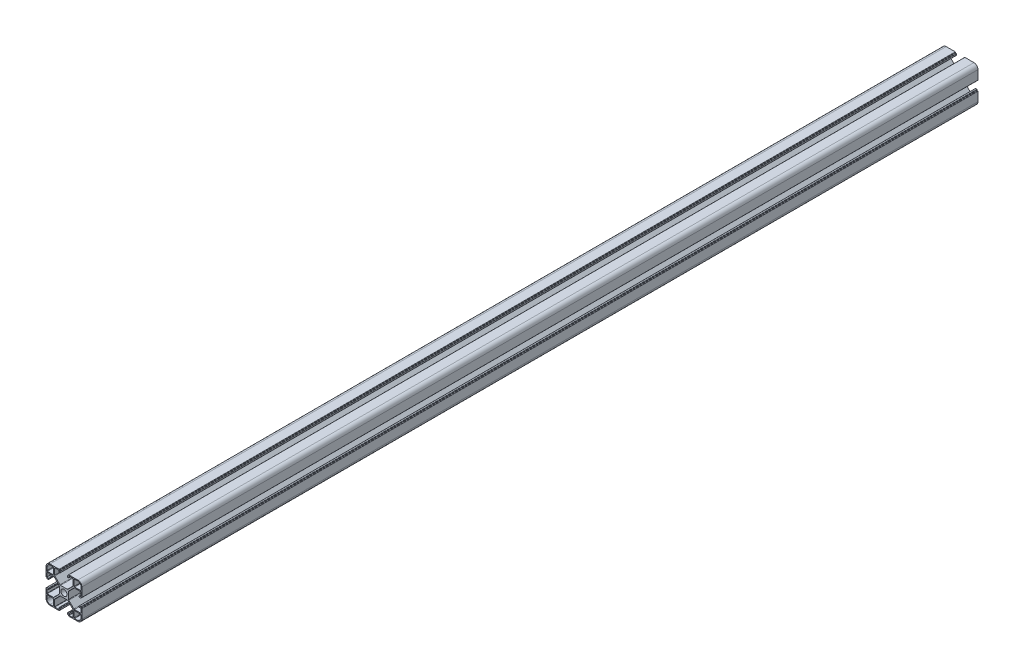
from build123d import *

# Parameters (mm, degrees)
SKETCH_1_R      = 3.4
EXTRUDE_1_DEPTH = 1000


with BuildPart() as part:
    # Эскиз1 → Бобышка-Вытянуть1 (new body)
    with BuildSketch(Plane.XY):
        with BuildLine():
            Line((-20, 10.4), (-20, 15.5))
            ThreePointArc((-20, 15.5), (-18.681980515, 18.681980515), (-15.5, 20))
            Line((-15.5, 20), (-10.4, 20))
            Line((-10.4, 20), (-5.4, 20))
            ThreePointArc((-5.4, 20), (-5.187867966, 19.912132034), (-5.1, 19.7))
            Line((-5.1, 19.7), (-5.1, 19.3))
            ThreePointArc((-5.1, 19.3), (-5.012132034, 19.087867966), (-4.8, 19))
            Line((-4.8, 19), (-4.4, 19))
            ThreePointArc((-4.4, 19), (-4.187867966, 18.912132034), (-4.1, 18.7))
            Line((-4.1, 18.7), (-4.1, 17.3))
            ThreePointArc((-4.1, 17.3), (-4.187867966, 17.087867966), (-4.4, 17))
            Line((-4.4, 17), (-5.3, 17))
            ThreePointArc((-5.3, 17), (-5.512132034, 17.087867966), (-5.6, 17.3))
            Line((-5.6, 17.3), (-5.6, 18.7))
            ThreePointArc((-5.6, 18.7), (-5.687867966, 18.912132034), (-5.9, 19))
            Line((-5.9, 19), (-10.1, 19))
            ThreePointArc((-10.1, 19), (-10.312132034, 18.912132034), (-10.4, 18.7))
            Line((-10.4, 18.7), (-10.4, 11.814213562))
            ThreePointArc((-10.4, 11.814213562), (-10.323879533, 11.43153013), (-10.107106781, 11.107106781))
            Line((-10.107106781, 11.107106781), (-4.492893219, 5.492893219))
            ThreePointArc((-4.492893219, 5.492893219), (-4.16846987, 5.276120467), (-3.785786438, 5.2))
            Line((-3.785786438, 5.2), (3.785786438, 5.2))
            ThreePointArc((3.785786438, 5.2), (4.16846987, 5.276120467), (4.492893219, 5.492893219))
            Line((4.492893219, 5.492893219), (10.107106781, 11.107106781))
            ThreePointArc((10.107106781, 11.107106781), (10.323879533, 11.43153013), (10.4, 11.814213562))
            Line((10.4, 11.814213562), (10.4, 18.7))
            ThreePointArc((10.4, 18.7), (10.312132034, 18.912132034), (10.1, 19))
            Line((10.1, 19), (5.9, 19))
            ThreePointArc((5.9, 19), (5.687867966, 18.912132034), (5.6, 18.7))
            Line((5.6, 18.7), (5.6, 17.3))
            ThreePointArc((5.6, 17.3), (5.512132034, 17.087867966), (5.3, 17))
            Line((5.3, 17), (4.4, 17))
            ThreePointArc((4.4, 17), (4.187867966, 17.087867966), (4.1, 17.3))
            Line((4.1, 17.3), (4.1, 18.7))
            ThreePointArc((4.1, 18.7), (4.187867966, 18.912132034), (4.4, 19))
            Line((4.4, 19), (4.8, 19))
            ThreePointArc((4.8, 19), (5.012132034, 19.087867966), (5.1, 19.3))
            Line((5.1, 19.3), (5.1, 19.7))
            ThreePointArc((5.1, 19.7), (5.187867966, 19.912132034), (5.4, 20))
            Line((5.4, 20), (10.4, 20))
            Line((10.4, 20), (15.5, 20))
            ThreePointArc((15.5, 20), (18.681980515, 18.681980515), (20, 15.5))
            Line((20, 15.5), (20, 10.4))
            Line((20, 10.4), (20, 5.4))
            ThreePointArc((20, 5.4), (19.912132034, 5.187867966), (19.7, 5.1))
            Line((19.7, 5.1), (19.3, 5.1))
            ThreePointArc((19.3, 5.1), (19.087867966, 5.012132034), (19, 4.8))
            Line((19, 4.8), (19, 4.4))
            ThreePointArc((19, 4.4), (18.912132034, 4.187867966), (18.7, 4.1))
            Line((18.7, 4.1), (17.3, 4.1))
            ThreePointArc((17.3, 4.1), (17.087867966, 4.187867966), (17, 4.4))
            Line((17, 4.4), (17, 5.3))
            ThreePointArc((17, 5.3), (17.087867966, 5.512132034), (17.3, 5.6))
            Line((17.3, 5.6), (18.7, 5.6))
            ThreePointArc((18.7, 5.6), (18.912132034, 5.687867966), (19, 5.9))
            Line((19, 5.9), (19, 10.1))
            ThreePointArc((19, 10.1), (18.912132034, 10.312132034), (18.7, 10.4))
            Line((18.7, 10.4), (11.814213562, 10.4))
            ThreePointArc((11.814213562, 10.4), (11.43153013, 10.323879533), (11.107106781, 10.107106781))
            Line((11.107106781, 10.107106781), (5.492893219, 4.492893219))
            ThreePointArc((5.492893219, 4.492893219), (5.276120467, 4.16846987), (5.2, 3.785786438))
            Line((5.2, 3.785786438), (5.2, -3.785786438))
            ThreePointArc((5.2, -3.785786438), (5.276120467, -4.16846987), (5.492893219, -4.492893219))
            Line((5.492893219, -4.492893219), (11.107106781, -10.107106781))
            ThreePointArc((11.107106781, -10.107106781), (11.43153013, -10.323879533), (11.814213562, -10.4))
            Line((11.814213562, -10.4), (18.7, -10.4))
            ThreePointArc((18.7, -10.4), (18.912132034, -10.312132034), (19, -10.1))
            Line((19, -10.1), (19, -5.9))
            ThreePointArc((19, -5.9), (18.912132034, -5.687867966), (18.7, -5.6))
            Line((18.7, -5.6), (17.3, -5.6))
            ThreePointArc((17.3, -5.6), (17.087867966, -5.512132034), (17, -5.3))
            Line((17, -5.3), (17, -4.4))
            ThreePointArc((17, -4.4), (17.087867966, -4.187867966), (17.3, -4.1))
            Line((17.3, -4.1), (18.7, -4.1))
            ThreePointArc((18.7, -4.1), (18.912132034, -4.187867966), (19, -4.4))
            Line((19, -4.4), (19, -4.8))
            ThreePointArc((19, -4.8), (19.087867966, -5.012132034), (19.3, -5.1))
            Line((19.3, -5.1), (19.7, -5.1))
            ThreePointArc((19.7, -5.1), (19.912132034, -5.187867966), (20, -5.4))
            Line((20, -5.4), (20, -10.4))
            Line((20, -10.4), (20, -15.5))
            ThreePointArc((20, -15.5), (18.681980515, -18.681980515), (15.5, -20))
            Line((15.5, -20), (10.4, -20))
            Line((10.4, -20), (5.4, -20))
            ThreePointArc((5.4, -20), (5.187867966, -19.912132034), (5.1, -19.7))
            Line((5.1, -19.7), (5.1, -19.3))
            ThreePointArc((5.1, -19.3), (5.012132034, -19.087867966), (4.8, -19))
            Line((4.8, -19), (4.4, -19))
            ThreePointArc((4.4, -19), (4.187867966, -18.912132034), (4.1, -18.7))
            Line((4.1, -18.7), (4.1, -17.3))
            ThreePointArc((4.1, -17.3), (4.187867966, -17.087867966), (4.4, -17))
            Line((4.4, -17), (5.3, -17))
            ThreePointArc((5.3, -17), (5.512132034, -17.087867966), (5.6, -17.3))
            Line((5.6, -17.3), (5.6, -18.7))
            ThreePointArc((5.6, -18.7), (5.687867966, -18.912132034), (5.9, -19))
            Line((5.9, -19), (10.1, -19))
            ThreePointArc((10.1, -19), (10.312132034, -18.912132034), (10.4, -18.7))
            Line((10.4, -18.7), (10.4, -11.814213562))
            ThreePointArc((10.4, -11.814213562), (10.323879533, -11.43153013), (10.107106781, -11.107106781))
            Line((10.107106781, -11.107106781), (4.492893219, -5.492893219))
            ThreePointArc((4.492893219, -5.492893219), (4.16846987, -5.276120467), (3.785786438, -5.2))
            Line((3.785786438, -5.2), (-3.785786438, -5.2))
            ThreePointArc((-3.785786438, -5.2), (-4.16846987, -5.276120467), (-4.492893219, -5.492893219))
            Line((-4.492893219, -5.492893219), (-10.107106781, -11.107106781))
            ThreePointArc((-10.107106781, -11.107106781), (-10.323879533, -11.43153013), (-10.4, -11.814213562))
            Line((-10.4, -11.814213562), (-10.4, -18.7))
            ThreePointArc((-10.4, -18.7), (-10.312132034, -18.912132034), (-10.1, -19))
            Line((-10.1, -19), (-5.9, -19))
            ThreePointArc((-5.9, -19), (-5.687867966, -18.912132034), (-5.6, -18.7))
            Line((-5.6, -18.7), (-5.6, -17.3))
            ThreePointArc((-5.6, -17.3), (-5.512132034, -17.087867966), (-5.3, -17))
            Line((-5.3, -17), (-4.4, -17))
            ThreePointArc((-4.4, -17), (-4.187867966, -17.087867966), (-4.1, -17.3))
            Line((-4.1, -17.3), (-4.1, -18.7))
            ThreePointArc((-4.1, -18.7), (-4.187867966, -18.912132034), (-4.4, -19))
            Line((-4.4, -19), (-4.8, -19))
            ThreePointArc((-4.8, -19), (-5.012132034, -19.087867966), (-5.1, -19.3))
            Line((-5.1, -19.3), (-5.1, -19.7))
            ThreePointArc((-5.1, -19.7), (-5.187867966, -19.912132034), (-5.4, -20))
            Line((-5.4, -20), (-10.4, -20))
            Line((-10.4, -20), (-15.5, -20))
            ThreePointArc((-15.5, -20), (-18.681980515, -18.681980515), (-20, -15.5))
            Line((-20, -15.5), (-20, -10.4))
            Line((-20, -10.4), (-20, -5.4))
            ThreePointArc((-20, -5.4), (-19.912132034, -5.187867966), (-19.7, -5.1))
            Line((-19.7, -5.1), (-19.3, -5.1))
            ThreePointArc((-19.3, -5.1), (-19.087867966, -5.012132034), (-19, -4.8))
            Line((-19, -4.8), (-19, -4.4))
            ThreePointArc((-19, -4.4), (-18.912132034, -4.187867966), (-18.7, -4.1))
            Line((-18.7, -4.1), (-17.3, -4.1))
            ThreePointArc((-17.3, -4.1), (-17.087867966, -4.187867966), (-17, -4.4))
            Line((-17, -4.4), (-17, -5.3))
            ThreePointArc((-17, -5.3), (-17.087867966, -5.512132034), (-17.3, -5.6))
            Line((-17.3, -5.6), (-18.7, -5.6))
            ThreePointArc((-18.7, -5.6), (-18.912132034, -5.687867966), (-19, -5.9))
            Line((-19, -5.9), (-19, -10.1))
            ThreePointArc((-19, -10.1), (-18.912132034, -10.312132034), (-18.7, -10.4))
            Line((-18.7, -10.4), (-11.814213562, -10.4))
            ThreePointArc((-11.814213562, -10.4), (-11.43153013, -10.323879533), (-11.107106781, -10.107106781))
            Line((-11.107106781, -10.107106781), (-5.492893219, -4.492893219))
            ThreePointArc((-5.492893219, -4.492893219), (-5.276120467, -4.16846987), (-5.2, -3.785786438))
            Line((-5.2, -3.785786438), (-5.2, 3.785786438))
            ThreePointArc((-5.2, 3.785786438), (-5.276120467, 4.16846987), (-5.492893219, 4.492893219))
            Line((-5.492893219, 4.492893219), (-11.107106781, 10.107106781))
            ThreePointArc((-11.107106781, 10.107106781), (-11.43153013, 10.323879533), (-11.814213562, 10.4))
            Line((-11.814213562, 10.4), (-18.7, 10.4))
            ThreePointArc((-18.7, 10.4), (-18.912132034, 10.312132034), (-19, 10.1))
            Line((-19, 10.1), (-19, 5.9))
            ThreePointArc((-19, 5.9), (-18.912132034, 5.687867966), (-18.7, 5.6))
            Line((-18.7, 5.6), (-17.3, 5.6))
            ThreePointArc((-17.3, 5.6), (-17.087867966, 5.512132034), (-17, 5.3))
            Line((-17, 5.3), (-17, 4.4))
            ThreePointArc((-17, 4.4), (-17.087867966, 4.187867966), (-17.3, 4.1))
            Line((-17.3, 4.1), (-18.7, 4.1))
            ThreePointArc((-18.7, 4.1), (-18.912132034, 4.187867966), (-19, 4.4))
            Line((-19, 4.4), (-19, 4.8))
            ThreePointArc((-19, 4.8), (-19.087867966, 5.012132034), (-19.3, 5.1))
            Line((-19.3, 5.1), (-19.7, 5.1))
            ThreePointArc((-19.7, 5.1), (-19.912132034, 5.187867966), (-20, 5.4))
            Line((-20, 5.4), (-20, 10.4))
        make_face()
        Circle(SKETCH_1_R, mode=Mode.SUBTRACT)
        with BuildLine():
            Line((-11.9, 11.4), (-18.5, 11.4))
            ThreePointArc((-18.5, 11.4), (-18.853553391, 11.546446609), (-19, 11.9))
            Line((-19, 11.9), (-19, 15.5))
            ThreePointArc((-19, 15.5), (-17.974873734, 17.974873734), (-15.5, 19))
            Line((-15.5, 19), (-11.9, 19))
            ThreePointArc((-11.9, 19), (-11.546446609, 18.853553391), (-11.4, 18.5))
            Line((-11.4, 18.5), (-11.4, 11.9))
            ThreePointArc((-11.4, 11.9), (-11.546446609, 11.546446609), (-11.9, 11.4))
        make_face(mode=Mode.SUBTRACT)
        with BuildLine():
            Line((11.4, 11.9), (11.4, 18.5))
            ThreePointArc((11.4, 18.5), (11.546446609, 18.853553391), (11.9, 19))
            Line((11.9, 19), (15.5, 19))
            ThreePointArc((15.5, 19), (17.974873734, 17.974873734), (19, 15.5))
            Line((19, 15.5), (19, 11.9))
            ThreePointArc((19, 11.9), (18.853553391, 11.546446609), (18.5, 11.4))
            Line((18.5, 11.4), (11.9, 11.4))
            ThreePointArc((11.9, 11.4), (11.546446609, 11.546446609), (11.4, 11.9))
        make_face(mode=Mode.SUBTRACT)
        with BuildLine():
            Line((11.9, -11.4), (18.5, -11.4))
            ThreePointArc((18.5, -11.4), (18.853553391, -11.546446609), (19, -11.9))
            Line((19, -11.9), (19, -15.5))
            ThreePointArc((19, -15.5), (17.974873734, -17.974873734), (15.5, -19))
            Line((15.5, -19), (11.9, -19))
            ThreePointArc((11.9, -19), (11.546446609, -18.853553391), (11.4, -18.5))
            Line((11.4, -18.5), (11.4, -11.9))
            ThreePointArc((11.4, -11.9), (11.546446609, -11.546446609), (11.9, -11.4))
        make_face(mode=Mode.SUBTRACT)
        with BuildLine():
            Line((-11.4, -11.9), (-11.4, -18.5))
            ThreePointArc((-11.4, -18.5), (-11.546446609, -18.853553391), (-11.9, -19))
            Line((-11.9, -19), (-15.5, -19))
            ThreePointArc((-15.5, -19), (-17.974873734, -17.974873734), (-19, -15.5))
            Line((-19, -15.5), (-19, -11.9))
            ThreePointArc((-19, -11.9), (-18.853553391, -11.546446609), (-18.5, -11.4))
            Line((-18.5, -11.4), (-11.9, -11.4))
            ThreePointArc((-11.9, -11.4), (-11.546446609, -11.546446609), (-11.4, -11.9))
        make_face(mode=Mode.SUBTRACT)
    extrude(amount=EXTRUDE_1_DEPTH)


solid = part.part
